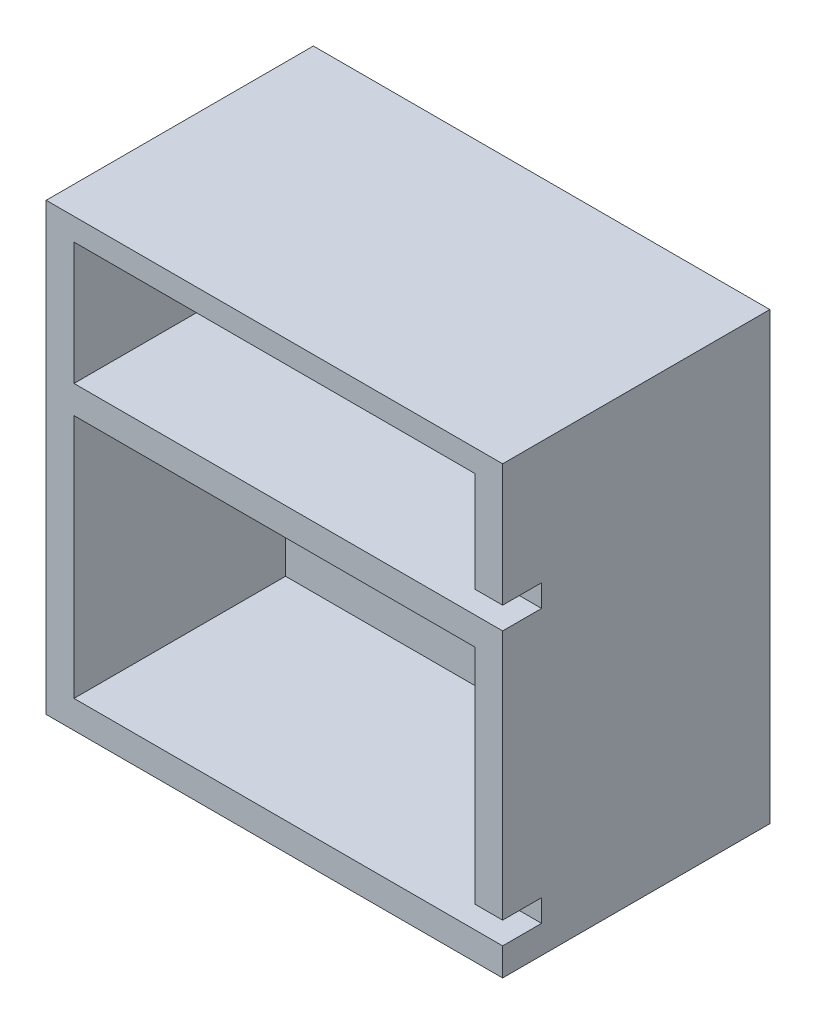
from build123d import *

# Parameters (mm, degrees)
SKETCH_1_W          = 82
SKETCH_1_H          = 48
EXTRUDE_1_DEPTH     = 80
SKETCH_2_W          = 72
SKETCH_2_H          = 44
SKETCH_2_H_2        = 22
CUT_EXTRUDE_1_DEPTH = 38
CUT_EXTRUDE_2_REACH = 84
SKETCH_3_W          = 7
SKETCH_3_H          = 4
SKETCH_5_R          = 3.6
CUT_EXTRUDE_3_DEPTH = 4.1
CUT_EXTRUDE_4_REACH = 12
SKETCH_6_R          = 2.25


with BuildPart() as part:
    # 草圖1 → 填料-伸長1 (new body)
    with BuildSketch(Plane(origin=(0, 0, 0), x_dir=(1, 0, 0), z_dir=(0, 1, 0))):
        Rectangle(SKETCH_1_W, SKETCH_1_H)
    extrude(amount=EXTRUDE_1_DEPTH)

    # 草圖2 → 除料-伸長1 (cut)
    with BuildSketch(Plane.XY.offset(24)):
        with Locations((0, 27)):
            Rectangle(SKETCH_2_W, SKETCH_2_H)
        with Locations((0, 65)):
            Rectangle(SKETCH_2_W, SKETCH_2_H_2)
    extrude(amount=-CUT_EXTRUDE_1_DEPTH, mode=Mode.SUBTRACT)

    # 草圖3 → 除料-伸長2 (cut, up to next)
    with BuildSketch(Plane(origin=(41, 0, 0), x_dir=(0, 0, -1), z_dir=(1, 0, 0)), mode=Mode.PRIVATE) as cut_extrude_2_sk1:
        with Locations((-20.5, 7)):
            Rectangle(SKETCH_3_W, SKETCH_3_H)
    cut_extrude_2_tool1 = extrude(cut_extrude_2_sk1.sketch, amount=-CUT_EXTRUDE_2_REACH, mode=Mode.PRIVATE) & part.part
    add(cut_extrude_2_tool1.solids().sort_by_distance((41, 7, 20.5))[0], mode=Mode.SUBTRACT)
    # 草圖3 → 除料-伸長2 (cut, up to next)
    with BuildSketch(Plane(origin=(41, 0, 0), x_dir=(0, 0, -1), z_dir=(1, 0, 0)), mode=Mode.PRIVATE) as cut_extrude_2_sk2:
        with Locations((-20.5, 56)):
            Rectangle(SKETCH_3_W, SKETCH_3_H)
    cut_extrude_2_tool2 = extrude(cut_extrude_2_sk2.sketch, amount=-CUT_EXTRUDE_2_REACH, mode=Mode.PRIVATE) & part.part
    add(cut_extrude_2_tool2.solids().sort_by_distance((41, 56, 20.5))[0], mode=Mode.SUBTRACT)

    # 草圖5 → 除料-伸長3 (cut)
    with BuildSketch(Plane.XY.offset(-14)):
        with Locations((-21, 60)):
            Circle(SKETCH_5_R)
        with Locations((15, 60)):
            Circle(SKETCH_5_R)
        with Locations((15, 24)):
            Circle(SKETCH_5_R)
        with Locations((-21, 24)):
            Circle(SKETCH_5_R)
    extrude(amount=-CUT_EXTRUDE_3_DEPTH, mode=Mode.SUBTRACT)

    # 草圖6 → 除料-伸長4 (cut, up to next)
    with BuildSketch(Plane.XY.offset(-14), mode=Mode.PRIVATE) as cut_extrude_4_sk1:
        with Locations((-21, 60)):
            Circle(SKETCH_6_R)
    cut_extrude_4_tool1 = extrude(cut_extrude_4_sk1.sketch, amount=-CUT_EXTRUDE_4_REACH, mode=Mode.PRIVATE) & part.part
    add(cut_extrude_4_tool1.solids().sort_by_distance((-21, 60, -14))[0], mode=Mode.SUBTRACT)
    # 草圖6 → 除料-伸長4 (cut, up to next)
    with BuildSketch(Plane.XY.offset(-14), mode=Mode.PRIVATE) as cut_extrude_4_sk2:
        with Locations((15, 60)):
            Circle(SKETCH_6_R)
    cut_extrude_4_tool2 = extrude(cut_extrude_4_sk2.sketch, amount=-CUT_EXTRUDE_4_REACH, mode=Mode.PRIVATE) & part.part
    add(cut_extrude_4_tool2.solids().sort_by_distance((15, 60, -14))[0], mode=Mode.SUBTRACT)
    # 草圖6 → 除料-伸長4 (cut, up to next)
    with BuildSketch(Plane.XY.offset(-14), mode=Mode.PRIVATE) as cut_extrude_4_sk3:
        with Locations((15, 24)):
            Circle(SKETCH_6_R)
    cut_extrude_4_tool3 = extrude(cut_extrude_4_sk3.sketch, amount=-CUT_EXTRUDE_4_REACH, mode=Mode.PRIVATE) & part.part
    add(cut_extrude_4_tool3.solids().sort_by_distance((15, 24, -14))[0], mode=Mode.SUBTRACT)
    # 草圖6 → 除料-伸長4 (cut, up to next)
    with BuildSketch(Plane.XY.offset(-14), mode=Mode.PRIVATE) as cut_extrude_4_sk4:
        with Locations((-21, 24)):
            Circle(SKETCH_6_R)
    cut_extrude_4_tool4 = extrude(cut_extrude_4_sk4.sketch, amount=-CUT_EXTRUDE_4_REACH, mode=Mode.PRIVATE) & part.part
    add(cut_extrude_4_tool4.solids().sort_by_distance((-21, 24, -14))[0], mode=Mode.SUBTRACT)


solid = part.part
